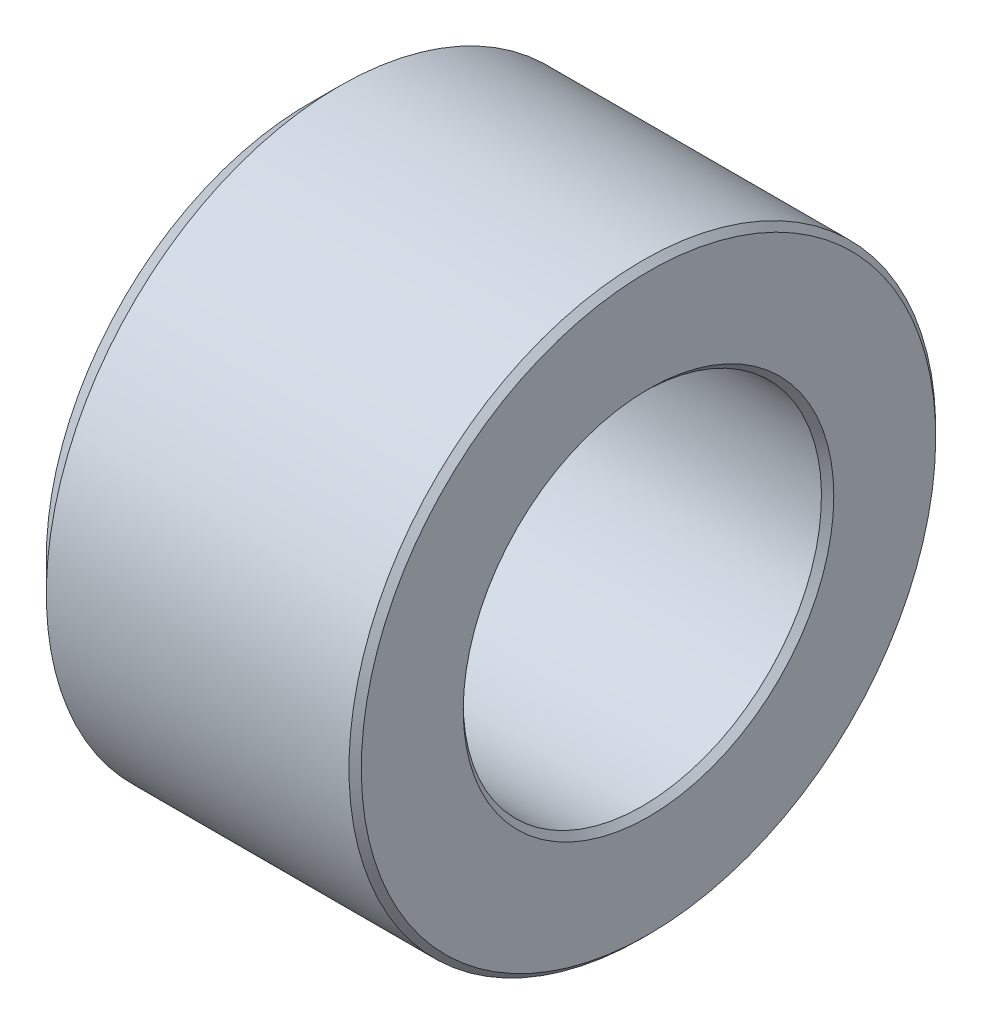
from build123d import *

# Parameters (mm, degrees)
ESQUISSE1_W     = 5.5
ESQUISSE1_H     = 1.85
CHANFREIN1_SIZE = 0.1
CHANFREIN2_SIZE = 0.5


with BuildPart() as part:
    # Esquisse1 → Révolution1 (revolve)
    with BuildSketch(Plane.XY):
        with Locations((0, 3.825)):
            Rectangle(ESQUISSE1_W, ESQUISSE1_H)
    revolve(axis=Axis((0, 0, 0), (-1, 0, 0)))

    # Chanfrein1
    chanfrein1_edges = [part.edges().sort_by_distance(p)[0] for p in [
        (2.75, -2.9, 0),
        (-2.75, -2.9, 0),
        (2.75, -4.75, 0),
    ]]
    chamfer(chanfrein1_edges, length=CHANFREIN1_SIZE)

    # Chanfrein2
    chanfrein2_edges = [part.edges().sort_by_distance(p)[0] for p in [
        (-2.75, -4.75, 0),
    ]]
    chamfer(chanfrein2_edges, length=CHANFREIN2_SIZE)


solid = part.part
